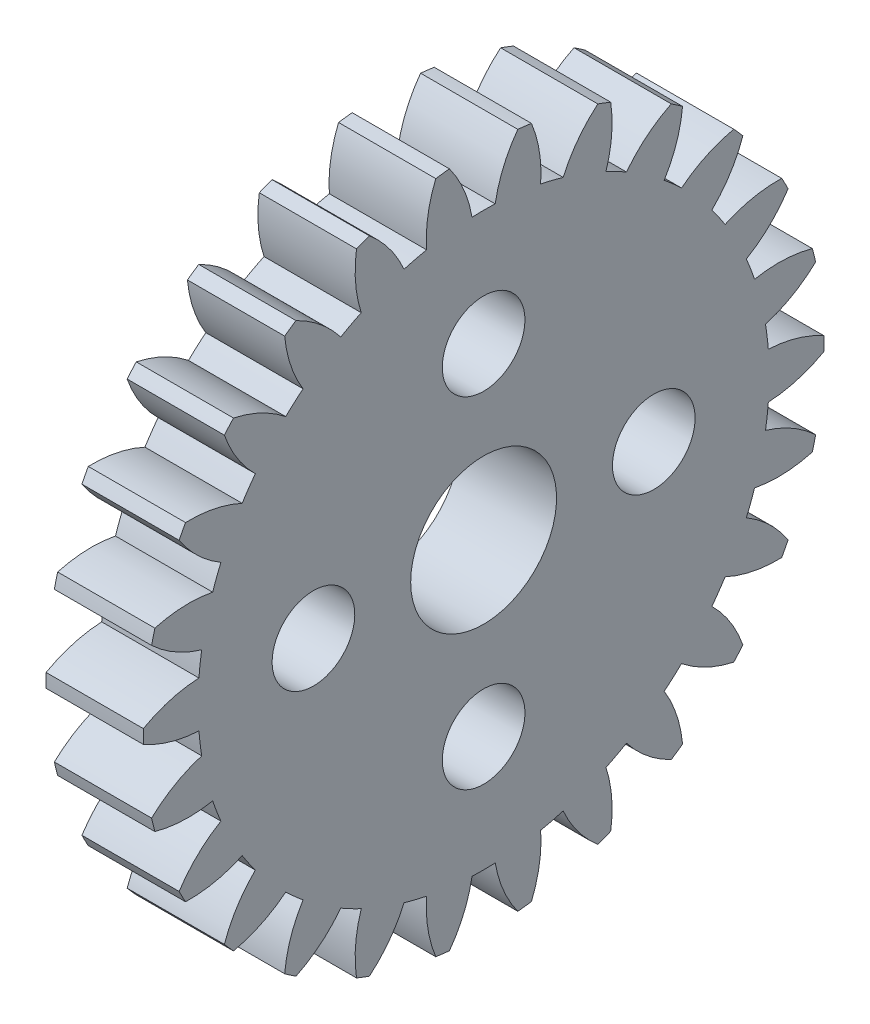
from build123d import *

# Parameters (mm, degrees)
BASPROSKE_W        = 4
BASPROSKE_H        = 14
TOOTHCUT_DEPTH     = 21.199009877
TEETHCUTS_COUNT    = 26
TEETHCUTS_ANGLE    = 346.153846154
BORSKE_R           = 3
BORE_DEPTH         = 50.0000508
HOLE_WIZARD_M3_1_D = 3.4
CIRPATTERN1_COUNT  = 4


with BuildPart() as part:
    # BasProSke → Base-Revolve (revolve)
    with BuildSketch(Plane(origin=(0, 0, 0), x_dir=(1, 0, 0), z_dir=(0, 1, 0)), mode=Mode.PRIVATE) as base_revolve_sk:
        with Locations((2, 7)):
            Rectangle(BASPROSKE_W, BASPROSKE_H)
    revolve(base_revolve_sk.sketch.rotate(Axis((-10, 0, 0), (1, 0, 0)), 180), axis=Axis((-10, 0, 0), (1, 0, 0)))

    # TooCutSke → ToothCut (cut, through all)
    with BuildSketch(Plane(origin=(0, 0, 0), x_dir=(0, 0, -1), z_dir=(1, 0, 0))):
        with BuildLine():
            ThreePointArc((0.476965065, 11.739314517), (0, 11.749), (-0.476965065, 11.739314517))
            ThreePointArc((-0.476965065, 11.739314517), (-0.82065865, 12.901686978), (-1.424117301, 13.952911348))
            ThreePointArc((-1.424117301, 13.952911348), (0, 14.0254), (1.424117301, 13.952911348))
            ThreePointArc((1.424117301, 13.952911348), (0.82065865, 12.901686978), (0.476965065, 11.739314517))
        make_face()
    toothcut = extrude(amount=TOOTHCUT_DEPTH, mode=Mode.SUBTRACT)

    # TeethCuts: ToothCut ×26 about axis
    teethcuts_axis = Axis((-10, 0, 0), (1, 0, 0))
    for i in range(1, TEETHCUTS_COUNT):
        add(toothcut.rotate(teethcuts_axis, i * TEETHCUTS_ANGLE / (TEETHCUTS_COUNT - 1)), mode=Mode.SUBTRACT)

    # BorSke → Bore (cut, symmetric)
    with BuildSketch(Plane(origin=(0, 0, 0), x_dir=(0, 0, -1), z_dir=(1, 0, 0))):
        with Locations(Location((0, 0, 0), (0, 0, 180))):
            Circle(BORSKE_R)
    extrude(amount=BORE_DEPTH, both=True, mode=Mode.SUBTRACT)

    # M3 餘隙孔1 (through all)
    with Locations(Plane(origin=(4, 0, 0), x_dir=(0, 0, -1), z_dir=(1, 0, 0))):
        with Locations((0, 7)):
            hole_wizard_m3_1 = Hole(HOLE_WIZARD_M3_1_D / 2)

    # CirPattern1: M3 餘隙孔1 ×4 about axis
    cirpattern1_axis = Axis((0, 0, 0), (1, 0, 0))
    for i in range(1, CIRPATTERN1_COUNT):
        add(hole_wizard_m3_1.rotate(cirpattern1_axis, i * 360 / CIRPATTERN1_COUNT), mode=Mode.SUBTRACT)


solid = part.part
